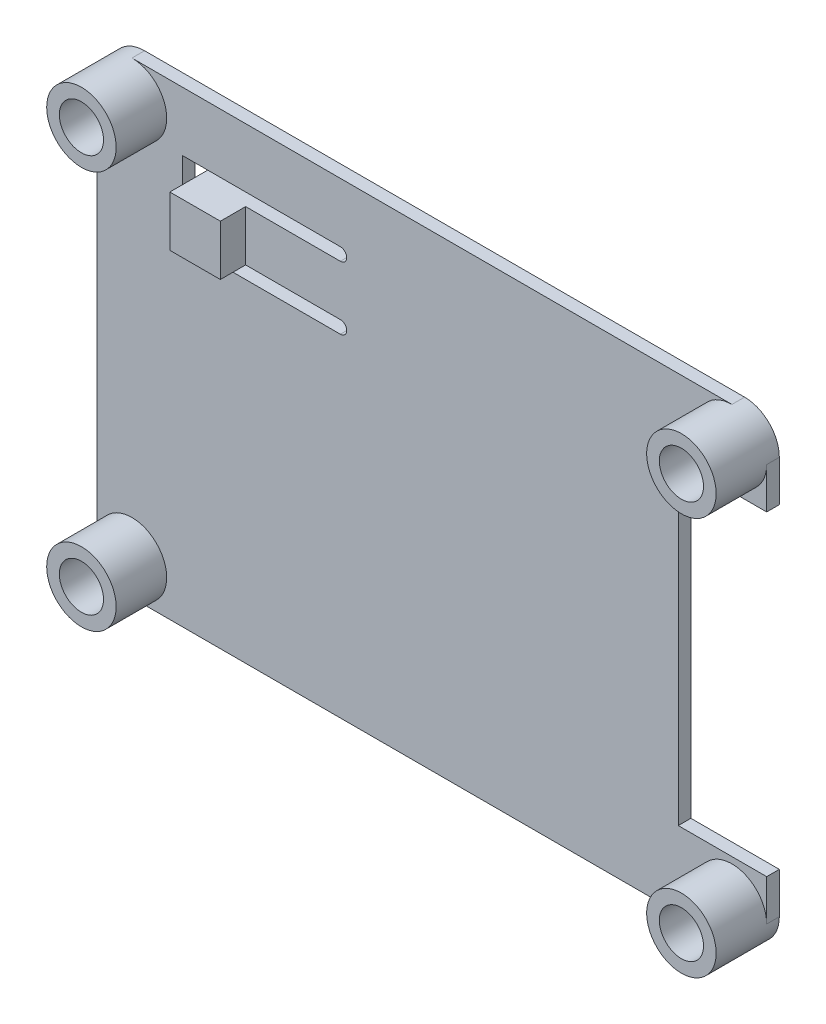
from build123d import *

# Parameters (mm, degrees)
ESBO_O1_R                = 2.75
ESBO_O1_R_2              = 1.75
RESSALTO_EXTRUS_O1_DEPTH = 1
ESBO_O1_3_R              = 2.75
ESBO_O1_3_R_2            = 1.75
RESSALTO_EXTRUS_O2_DEPTH = 5
ESBO_O2_W                = 7
ESBO_O2_H                = 25
CORTE_EXTRUS_O1_DEPTH    = 6
CORTE_EXTRUS_O2_DEPTH    = 6
ESBO_O4_W                = 4
ESBO_O4_H                = 4
RESSALTO_EXTRUS_O3_DEPTH = 2


with BuildPart() as part:
    # Esboço1 → Ressalto-extrusão1 (new body)
    with BuildSketch(Plane.XY):
        with BuildLine():
            Line((23.75, 18.5), (-23.75, 18.5))
            ThreePointArc((-23.75, 18.5), (-21.805456352, 17.694543648), (-21, 15.75))
            ThreePointArc((-21, 15.75), (-23.75, 13), (-26.5, 15.75))
            Line((-26.5, 15.75), (-26.5, -15.75))
            ThreePointArc((-26.5, -15.75), (-23.75, -13), (-21, -15.75))
            ThreePointArc((-21, -15.75), (-21.805456352, -17.694543648), (-23.75, -18.5))
            Line((-23.75, -18.5), (23.75, -18.5))
            ThreePointArc((23.75, -18.5), (21.805456352, -13.805456352), (26.5, -15.75))
            Line((26.5, -15.75), (26.5, 15.75))
            ThreePointArc((26.5, 15.75), (21.805456352, 13.805456352), (23.75, 18.5))
        make_face()
        with Locations((23.75, 15.75)):
            Circle(ESBO_O1_R)
        with Locations((23.75, 15.75)):
            Circle(ESBO_O1_R_2, mode=Mode.SUBTRACT)
        with Locations((23.75, -15.75)):
            Circle(ESBO_O1_R)
        with Locations((23.75, -15.75)):
            Circle(ESBO_O1_R_2, mode=Mode.SUBTRACT)
        with Locations((-23.75, -15.75)):
            Circle(ESBO_O1_R)
        with Locations((-23.75, -15.75)):
            Circle(ESBO_O1_R_2, mode=Mode.SUBTRACT)
        with Locations((-23.75, 15.75)):
            Circle(ESBO_O1_R)
        with Locations((-23.75, 15.75)):
            Circle(ESBO_O1_R_2, mode=Mode.SUBTRACT)
    extrude(amount=RESSALTO_EXTRUS_O1_DEPTH)

    # Esboço1<3> → Ressalto-extrusão2 (add)
    with BuildSketch(Plane.XY):
        with Locations((-23.75, 15.75)):
            Circle(ESBO_O1_3_R)
        with Locations((-23.75, 15.75)):
            Circle(ESBO_O1_3_R_2, mode=Mode.SUBTRACT)
        with Locations((23.75, 15.75)):
            Circle(ESBO_O1_3_R)
        with Locations((23.75, 15.75)):
            Circle(ESBO_O1_3_R_2, mode=Mode.SUBTRACT)
        with Locations((23.75, -15.75)):
            Circle(ESBO_O1_3_R)
        with Locations((23.75, -15.75)):
            Circle(ESBO_O1_3_R_2, mode=Mode.SUBTRACT)
        with Locations((-23.75, -15.75)):
            Circle(ESBO_O1_3_R)
        with Locations((-23.75, -15.75)):
            Circle(ESBO_O1_3_R_2, mode=Mode.SUBTRACT)
    extrude(amount=RESSALTO_EXTRUS_O2_DEPTH)

    # Esboço2 → Corte-extrusão1 (cut)
    with BuildSketch(Plane.XY.offset(1)):
        with Locations((23, 0)):
            Rectangle(ESBO_O2_W, ESBO_O2_H)
    extrude(amount=-CORTE_EXTRUS_O1_DEPTH, mode=Mode.SUBTRACT)

    # Esboço3 → Corte-extrusão2 (cut)
    with BuildSketch(Plane(origin=(0, 0, 0), x_dir=(-1, 0, 0), z_dir=(0, 0, -1))):
        with BuildLine():
            Line((7.25, 12.814331343), (18.75, 12.814331343))
            Line((18.75, 12.814331343), (18.75, 8.814331343))
            Line((18.75, 8.814331343), (7.25, 8.814331343))
            ThreePointArc((7.25, 8.814331343), (6.75, 8.314331343), (7.25, 7.814331343))
            Line((7.25, 7.814331343), (19.75, 7.814331343))
            Line((19.75, 7.814331343), (19.75, 13.814331343))
            Line((19.75, 13.814331343), (7.25, 13.814331343))
            ThreePointArc((7.25, 13.814331343), (6.75, 13.314331343), (7.25, 12.814331343))
        make_face()
    extrude(amount=-CORTE_EXTRUS_O2_DEPTH, mode=Mode.SUBTRACT)

    # Esboço4 → Ressalto-extrusão3 (add)
    with BuildSketch(Plane.XY.offset(1)):
        with Locations((-16.75, 10.814331343)):
            Rectangle(ESBO_O4_W, ESBO_O4_H)
    extrude(amount=RESSALTO_EXTRUS_O3_DEPTH)


solid = part.part
